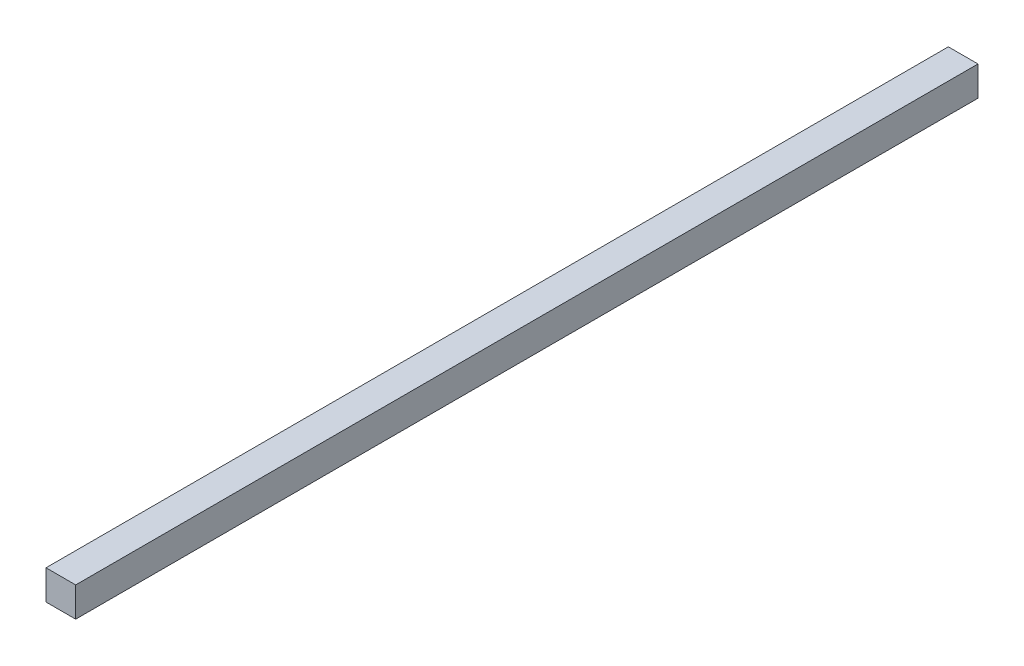
from build123d import *

# Parameters (mm, degrees)
SKETCH1_W           = 386.08
SKETCH1_H           = 12.7
BOSS_EXTRUDE1_DEPTH = 12.7


with BuildPart() as part:
    # Sketch1 → Boss-Extrude1 (new body)
    with BuildSketch(Plane(origin=(0, 0, 0), x_dir=(0, 0, -1), z_dir=(1, 0, 0))):
        with Locations((193.04, 6.35)):
            Rectangle(SKETCH1_W, SKETCH1_H)
    extrude(amount=BOSS_EXTRUDE1_DEPTH)


solid = part.part
